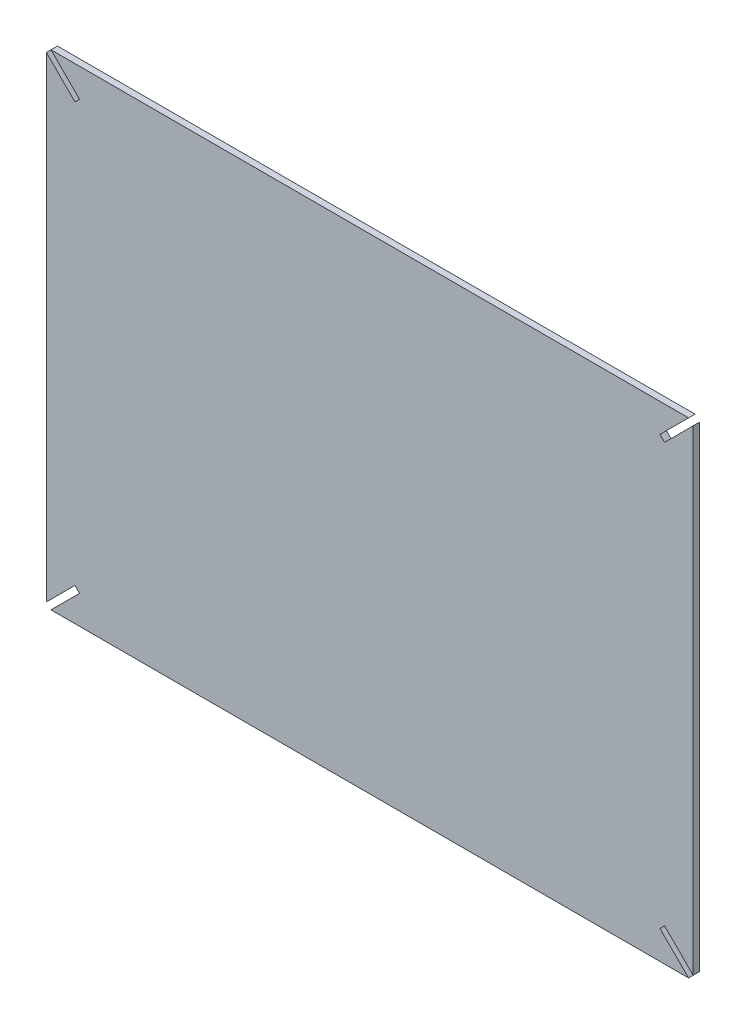
from build123d import *

# Parameters (mm, degrees)
BOSS_EXTRU_1_DEPTH = 4


with BuildPart() as part:
    # Esquisse1 → Boss.-Extru.1 (new body)
    with BuildSketch(Plane.XY):
        Polygon((-435.113026763, 131.24911262), (-40.769881012, 131.24911262), (-58.447550542, 113.57144309), (-55.619123417, 110.743015965), (-37.941453887, 128.420685495), (-37.941453887, -165.922460256), (-55.619123417, -148.244790726), (-58.447550542, -151.073217851), (-40.769881012, -168.75088738), (-435.113026763, -168.75088738), (-417.435357233, -151.073217851), (-420.263784358, -148.244790726), (-437.941453887, -165.922460256), (-437.941453887, 128.420685495), (-420.263784358, 110.743015965), (-417.435357233, 113.57144309), align=None)
    extrude(amount=BOSS_EXTRU_1_DEPTH)


solid = part.part
